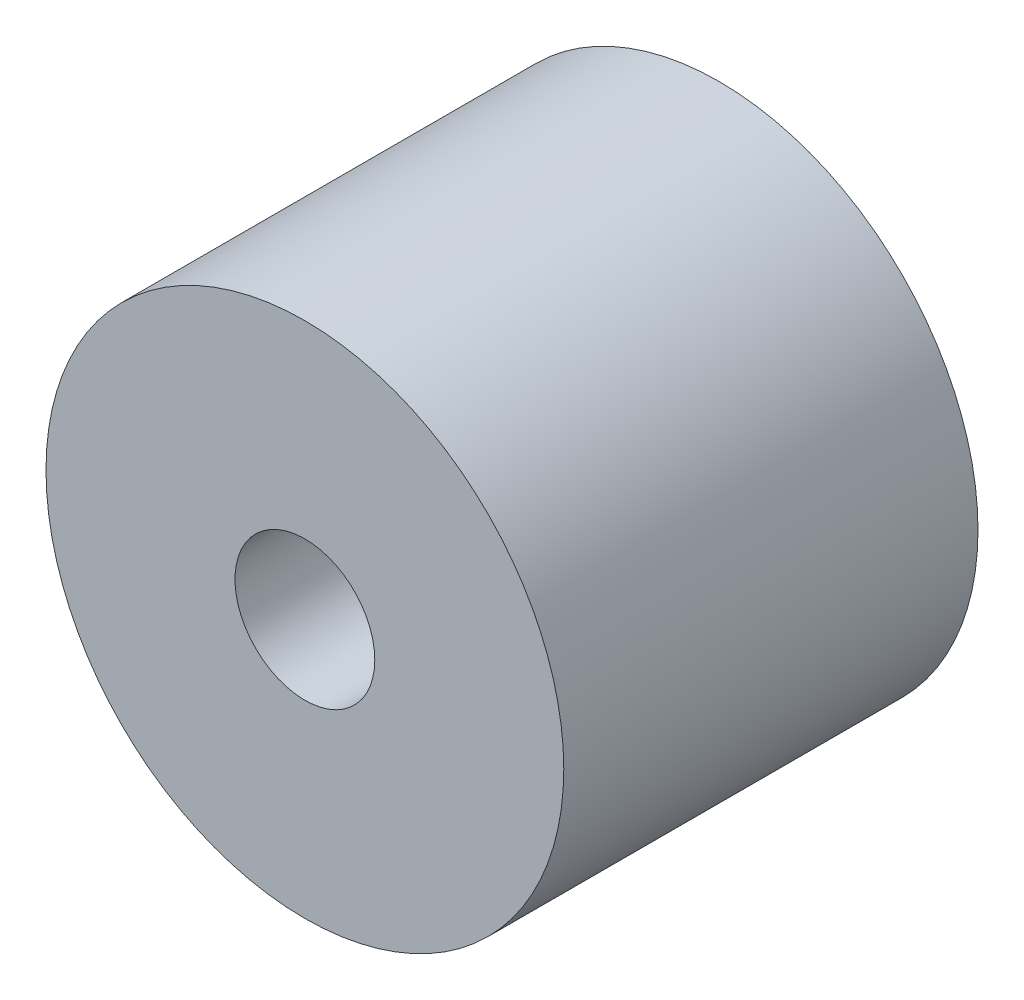
from build123d import *

# Parameters (mm, degrees)
SKETCH1_R                    = 6.35
BOSS_EXTRUDE1_DEPTH          = 10.16
F_1_4_0_135_DIAMETER_HOLE1_D = 3.429


with BuildPart() as part:
    # Sketch1 → Boss-Extrude1 (new body)
    with BuildSketch(Plane.XY):
        Circle(SKETCH1_R)
    extrude(amount=-BOSS_EXTRUDE1_DEPTH)

    # 1_4 _0.135_ Diameter Hole1 (through all)
    with Locations(Plane.XY):
        with Locations((0, 0)):
            Hole(F_1_4_0_135_DIAMETER_HOLE1_D / 2)


solid = part.part
